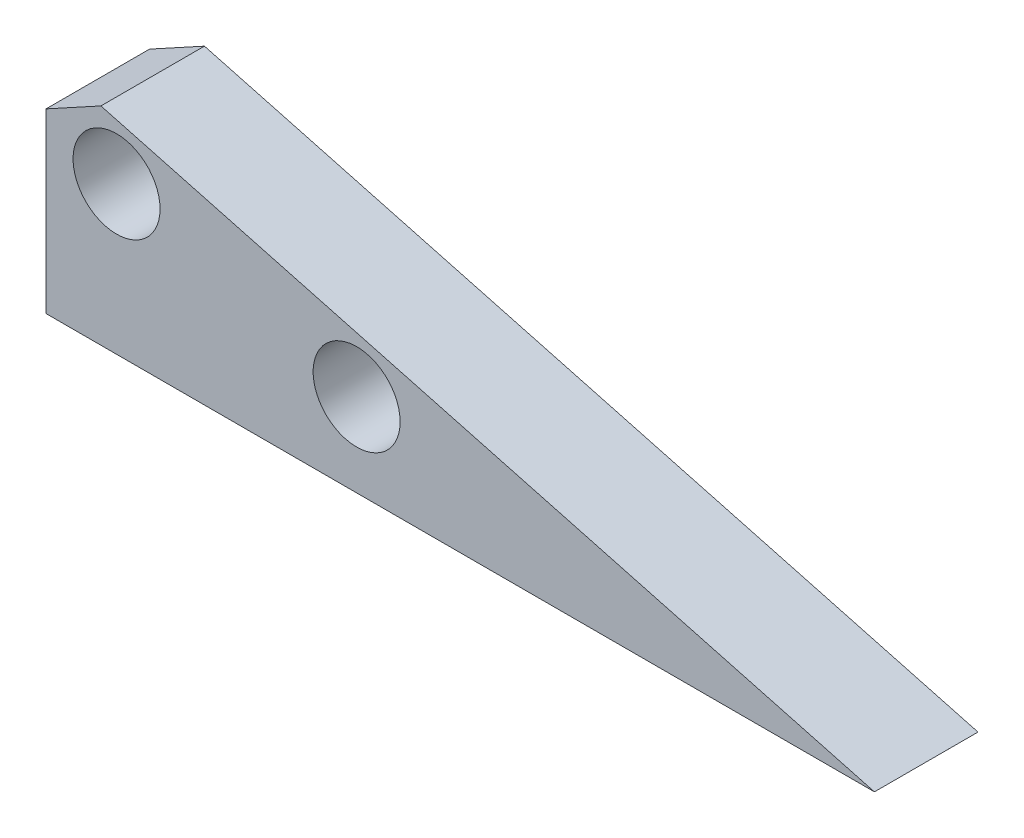
from build123d import *

# Parameters (mm, degrees)
SKETCH_8_R      = 2.1
EXTRUDE_6_DEPTH = 5


with BuildPart() as part:
    # 草图8 → 凸台-拉伸6 (new body)
    with BuildSketch(Plane.XY):
        Polygon((0, 0), (40, 0), (2.651084003, 10.00761403), (0, 8.558252816), align=None)
        with Locations((3.406885567, 7.12453076)):
            Circle(SKETCH_8_R, mode=Mode.SUBTRACT)
        with Locations((14.997995315, 4.018701596)):
            Circle(SKETCH_8_R, mode=Mode.SUBTRACT)
    extrude(amount=EXTRUDE_6_DEPTH)


solid = part.part
